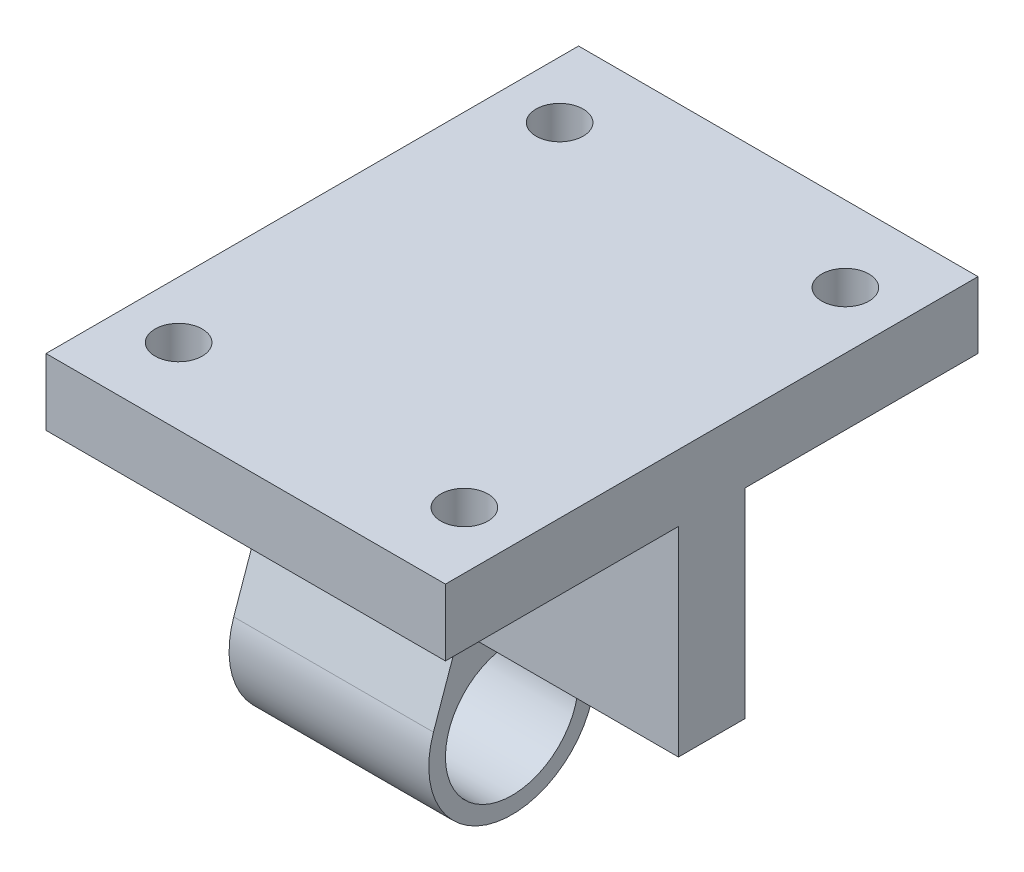
from build123d import *

# Parameters (mm, degrees)
BOSS_EXTRUDE1_DEPTH = 38.1
SKETCH2_R           = 6.35
BOSS_EXTRUDE2_DEPTH = 19.05
SKETCH3_R           = 2.2479
CUT_EXTRUDE1_DEPTH  = 42.275


with BuildPart() as part:
    # Sketch1 → Boss-Extrude1 (new body)
    with BuildSketch(Plane(origin=(0, 0, 0), x_dir=(0, 0, -1), z_dir=(1, 0, 0))):
        Polygon((-3.175, 0), (3.175, 0), (3.175, 19.05), (25.4, 19.05), (25.4, 25.4), (-25.4, 25.4), (-25.4, 19.05), (-3.175, 19.05), align=None)
    extrude(amount=BOSS_EXTRUDE1_DEPTH)

    # Sketch2 → Boss-Extrude2 (add)
    with BuildSketch(Plane.ZY):
        with BuildLine():
            ThreePointArc((-7.490824128, -5.312340931), (0, -15.875), (7.490824128, -5.312340931))
            Line((7.490824128, -5.312340931), (3.532340698, 5.983090093))
            ThreePointArc((3.532340698, 5.983090093), (3.264972581, 7.018061624), (3.175, 8.083217348))
            Line((3.175, 8.083217348), (3.175, 7.002752616))
            Line((3.175, 7.002752616), (3.175, 0))
            Line((3.175, 0), (-3.175, 0))
            Line((-3.175, 0), (-3.175, 7.002752616))
            Line((-3.175, 7.002752616), (-3.175, 8.083217348))
            ThreePointArc((-3.175, 8.083217348), (-3.264972581, 7.018061624), (-3.532340698, 5.983090093))
            Line((-3.532340698, 5.983090093), (-7.490824128, -5.312340931))
        make_face()
        with Locations((0, -7.9375)):
            Circle(SKETCH2_R, mode=Mode.SUBTRACT)
    extrude(amount=-BOSS_EXTRUDE2_DEPTH)

    # Sketch3 → Cut-Extrude1 (cut, through all)
    with BuildSketch(Plane(origin=(0, 25.4, 0), x_dir=(1, 0, 0), z_dir=(0, 1, 0))):
        with Locations((5.4229, 18.169466667)):
            Circle(SKETCH3_R)
        with Locations((32.6771, 18.169466667)):
            Circle(SKETCH3_R)
        with Locations((32.6771, -18.169466667)):
            Circle(SKETCH3_R)
        with Locations((5.4229, -18.169466667)):
            Circle(SKETCH3_R)
    extrude(amount=-CUT_EXTRUDE1_DEPTH, mode=Mode.SUBTRACT)


solid = part.part
